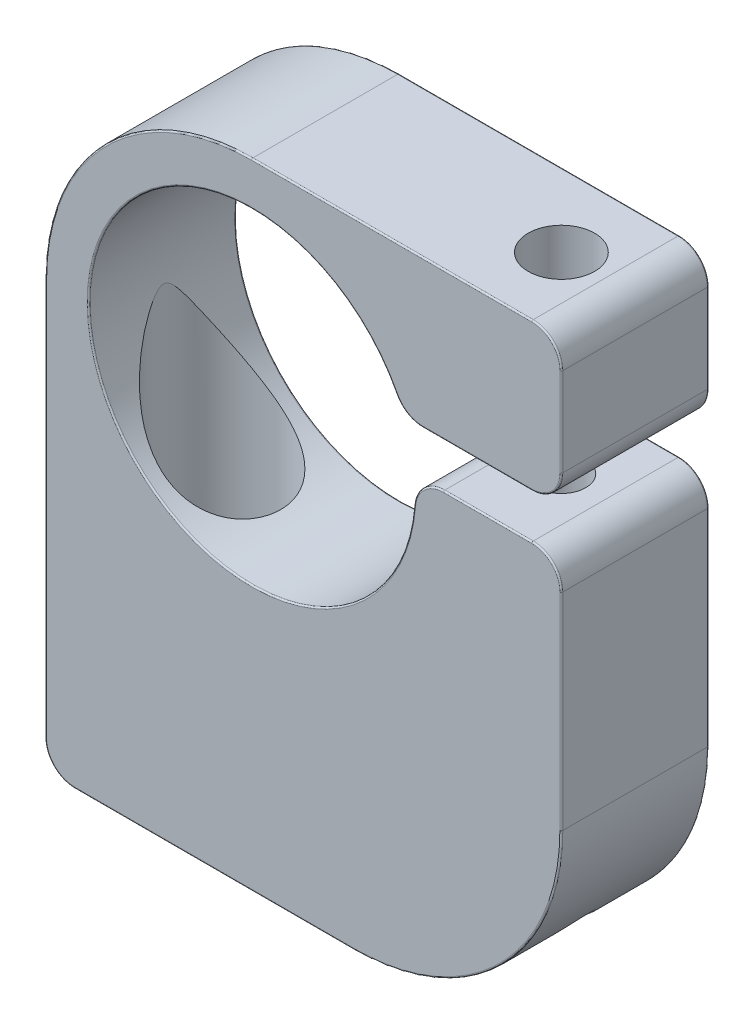
from build123d import *

# Parameters (mm, degrees)
EXTRUDE_1_DEPTH            = 10
HOLE_WIZARD_M41_D          = 4.5
HOLE_WIZARD_M41_DEPTH      = 4
HOLE_WIZARD_M41_TIP        = 1.351936393
SKETCH_5_W                 = 1.65
SKETCH_5_H                 = 30
HOLE_WIZARD_3_8_161_REACH  = 50.888
HOLE_WIZARD_3_8_161_BORE_R = 3.96875
FILLET_1_R                 = 2
FILLET_2_R                 = 0.1


with BuildPart() as part:
    # Эскиз1 → Бобышка-Вытянуть1 (new body)
    with BuildSketch(Plane.XY):
        with BuildLine():
            Line((10.300606778, 4), (21, 4))
            Line((21, 4), (21, 14))
            Line((21, 14), (0, 14))
            ThreePointArc((0, 14), (-9.899494937, 9.899494937), (-14, 0))
            Line((-14, 0), (-14, -29))
            Line((-14, -29), (7, -29))
            ThreePointArc((7, -29), (16.899494937, -24.899494937), (21, -15))
            Line((21, -15), (21, 1))
            Line((21, 1), (11.004658105, 1))
            ThreePointArc((11.004658105, 1), (-10.757721782, -2.524662763), (10.300606778, 4))
        make_face()
    extrude(amount=EXTRUDE_1_DEPTH)

    # Отверстие с зазором M41
    with Locations(Plane(origin=(0, 14, 0), x_dir=(1, 0, 0), z_dir=(0, 1, 0))):
        with Locations((16, -5)):
            Hole(HOLE_WIZARD_M41_D / 2, depth=HOLE_WIZARD_M41_DEPTH)
            with Locations((0, 0, -(HOLE_WIZARD_M41_DEPTH + HOLE_WIZARD_M41_TIP / 2))):  # 118° drill point
                Cone(0, HOLE_WIZARD_M41_D / 2, HOLE_WIZARD_M41_TIP, mode=Mode.SUBTRACT)

    # Эскиз5 → Отверстие обработанное метчиком M4x0.71 (revolve, cut)
    with BuildSketch(Plane(origin=(16, 1, 5), x_dir=(0, 0, 1), z_dir=(1, 0, 0))):
        with Locations((0.825, 15)):
            Rectangle(SKETCH_5_W, SKETCH_5_H)
    revolve(axis=Axis((16, 7.35, 5), (0, -1, 0)), mode=Mode.SUBTRACT)

    # Отверстие обработанное метчиком 3/8-161 bore → Отверстие обработанное метчиком 3/8-161 (cut, up to next)
    with BuildSketch(Plane(origin=(0, -29, 0), x_dir=(-1, 0, 0), z_dir=(0, -1, 0)), mode=Mode.PRIVATE) as hole_wizard_3_8_161_sk1:
        with Locations((7, -5)):
            Circle(HOLE_WIZARD_3_8_161_BORE_R)
    hole_wizard_3_8_161_tool1 = extrude(hole_wizard_3_8_161_sk1.sketch, amount=-HOLE_WIZARD_3_8_161_REACH, mode=Mode.PRIVATE) & part.part
    add(hole_wizard_3_8_161_tool1.solids().sort_by_distance((-7, -29, 5))[0], mode=Mode.SUBTRACT)

    # Скругление1
    fillet_1_edges = [part.edges().sort_by_distance(p)[0] for p in [
        (11.004658105, 1, 5),
        (21, 1, 5),
        (-14, -29, 5),
        (21, 14, 5),
        (21, 4, 5),
        (10.300606778, 4, 5),
    ]]
    fillet(fillet_1_edges, radius=FILLET_1_R)

    # Скругление2
    fillet_2_edges = [part.edges().sort_by_distance(p)[0] for p in [
        (16.899494937, -24.899494937, 0),
        (-14, -13.5, 0),
        (-9.899494937, 9.899494937, 0),
        (-9.899494937, 9.899494937, 10),
        (-14, -13.5, 10),
        (16.899494937, -24.899494937, 10),
        (21, -8, 10),
        (-2.5, -29, 0),
        (-2.5, -29, 10),
        (-10.828600624, -2.20088812, 0),
        (16.005814707, 1, 0),
        (9.5, 14, 0),
        (21, 9, 0),
        (15.294447774, 4, 0),
        (10.549443879, 4.291333786, 0),
        (11.652680079, 0.467397937, 0),
        (20.414213562, 0.414213562, 0),
        (20.414213562, 4.585786438, 0),
        (20.414213562, 13.414213562, 0),
        (-13.414213562, -28.414213562, 0),
        (-10.828600624, -2.20088812, 10),
        (15.294447774, 4, 10),
        (21, 9, 10),
        (9.5, 14, 10),
        (16.005814707, 1, 10),
        (10.549443879, 4.291333786, 10),
        (11.652680079, 0.467397937, 10),
        (20.414213562, 0.414213562, 10),
        (20.414213562, 4.585786438, 10),
        (20.414213562, 13.414213562, 10),
        (-13.414213562, -28.414213562, 10),
        (21, -8, 0),
    ]]
    fillet(fillet_2_edges, radius=FILLET_2_R)


solid = part.part
